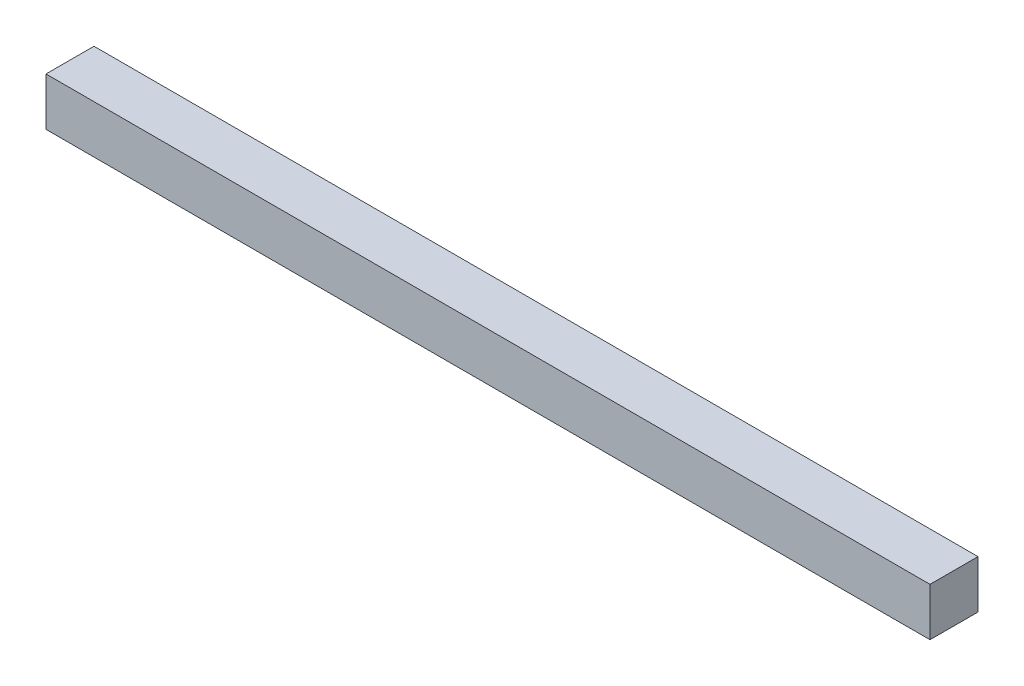
from build123d import *

# Parameters (mm, degrees)
SKETCH1_W           = 38.1
SKETCH1_H           = 38.1
BOSS_EXTRUDE1_DEPTH = 701.675


with BuildPart() as part:
    # Sketch1 → Boss-Extrude1 (new body)
    with BuildSketch(Plane(origin=(0, 0, 0), x_dir=(0, 0, -1), z_dir=(1, 0, 0))):
        Rectangle(SKETCH1_W, SKETCH1_H)
    extrude(amount=BOSS_EXTRUDE1_DEPTH)


solid = part.part
